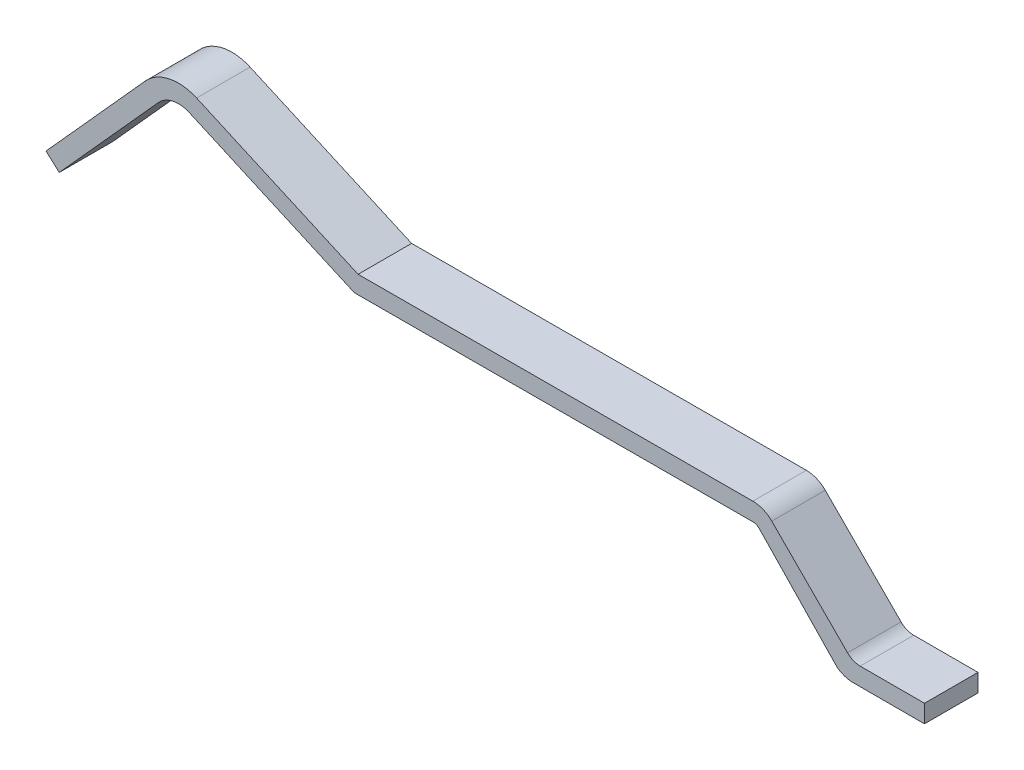
from build123d import *

# Parameters (mm, degrees)
RESSALTO_EXTRUS_O1_DEPTH = 0.3


with BuildPart() as part:
    # Esboço1 → Ressalto-extrusão1 (new body, symmetric)
    with BuildSketch(Plane.XY):
        with BuildLine():
            Line((18.8, 0.2), (18.8, 0))
            Line((18.8, 0), (18, 0))
            ThreePointArc((18, 0), (17.90513167, 0.015395011), (17.82, 0.06))
            Line((17.82, 0.06), (16.946446609, 0.970710678))
            ThreePointArc((16.946446609, 0.970710678), (16.914021314, 0.992429091), (16.875735931, 1))
            Line((16.875735931, 1), (12.407488688, 0.99))
            Line((12.407488688, 0.99), (10.557971552, 1.813458083))
            ThreePointArc((10.557971552, 1.813458083), (10.373577052, 1.832838725), (10.213007112, 1.740133627))
            Line((10.213007112, 1.740133627), (9.099531826, 0.503494039))
            Line((9.099531826, 0.503494039), (8.95090286, 0.637320161))
            Line((8.95090286, 0.637320161), (10.064378147, 1.873959748))
            ThreePointArc((10.064378147, 1.873959748), (10.331994714, 2.028468246), (10.639318881, 1.996167174))
            Line((10.639318881, 1.996167174), (12.45, 1.19))
            Line((12.45, 1.19), (16.875735931, 1.2))
            ThreePointArc((16.875735931, 1.2), (16.990592571, 1.177288457), (17.087867966, 1.112132034))
            Line((17.087867966, 1.112132034), (17.937254364, 0.258898547))
            ThreePointArc((17.937254364, 0.258898547), (18.002249513, 0.215310679), (18.078994902, 0.2))
            Line((18.078994902, 0.2), (18.8, 0.2))
        make_face()
    extrude(amount=RESSALTO_EXTRUS_O1_DEPTH, both=True)


solid = part.part
